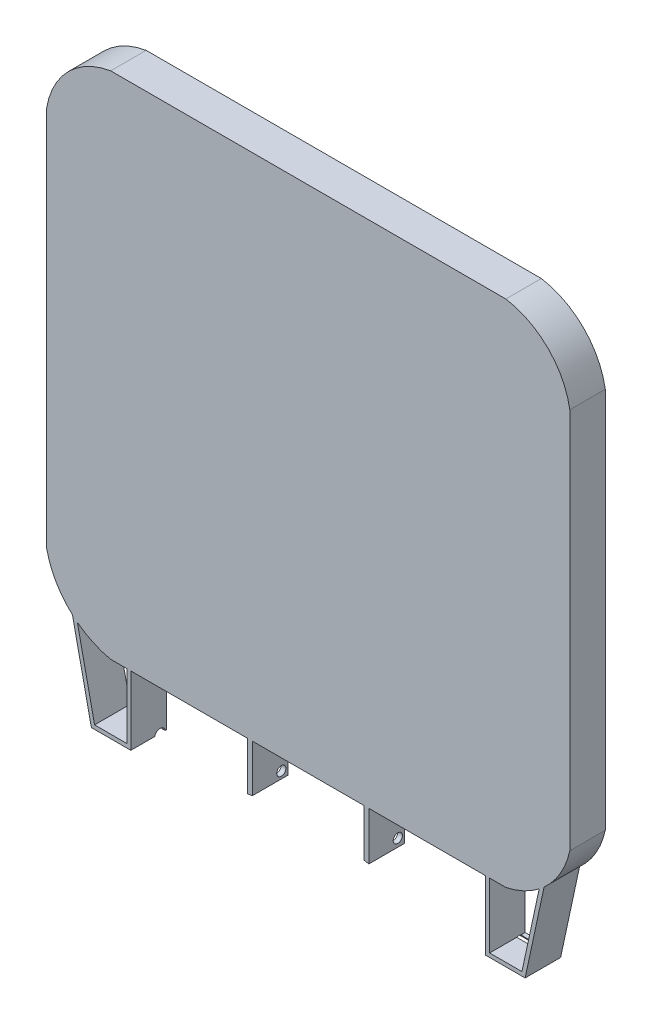
from build123d import *

# Parameters (mm, degrees)
BOSS_EXTRUDE1_DEPTH     = 25
BOSS_EXTRUDE2_DEPTH     = 2
BOSS_EXTRUDE3_DEPTH     = 27
SKETCH4_R               = 4.000000001
CUT_EXTRUDE1_DEPTH      = 290
CUT_EXTRUDE1_DEPTH_BACK = 10
BOSS_EXTRUDE4_DEPTH     = 27
SKETCH6_R               = 3.5
CUT_EXTRUDE2_DEPTH      = 108


with BuildPart() as part:
    # Sketch1 → Boss-Extrude1 (new body)
    with BuildSketch(Plane.XY):
        with BuildLine():
            Line((-199, 125.145211216), (-199, -165.423939983))
            ThreePointArc((-199, -165.423939983), (-181.870436917, -196.8510269), (-150.43197765, -213.959708975))
            Line((-150.43197765, -213.959708975), (150.431977646, -213.959708975))
            ThreePointArc((150.431977646, -213.959708975), (181.870436916, -196.8510269), (199, -165.423939981))
            Line((199, -165.423939981), (199, 125.145211216))
            ThreePointArc((199, 125.145211216), (182.477306779, 157.278075491), (150.333498342, 173.779467463))
            Line((150.333498342, 173.779467463), (-150.333498342, 173.779467463))
            ThreePointArc((-150.333498342, 173.779467463), (-182.477306779, 157.278075491), (-199, 125.145211216))
        make_face()
        with BuildLine():
            Line((-195, 124.810354463), (-195, -164.990595976))
            add(Edge.make_bspline(
                [(-195, -164.990595976), (-195, -209.959708976), (-150, -209.959708975)],
                knots=[3.141592654, 3.141592654, 3.141592654, 4.71238898, 4.71238898, 4.71238898], degree=2, weights=[1, 0.707106781, 1]))
            Line((-150, -209.959708975), (149.999999997, -209.959708975))
            add(Edge.make_bspline(
                [(149.999999997, -209.959708975), (195.000000002, -209.959708979), (195, -164.990595974)],
                knots=[4.71238898, 4.71238898, 4.71238898, 6.283185307, 6.283185307, 6.283185307], degree=2, weights=[1, 0.707106781, 1]))
            Line((195, -164.990595974), (195, 124.810354463))
            add(Edge.make_bspline(
                [(195, 124.810354463), (195, 169.779467463), (150, 169.779467463)],
                knots=[3.141592654, 3.141592654, 3.141592654, 4.71238898, 4.71238898, 4.71238898], degree=2, weights=[1, 0.707106781, 1]))
            Line((150, 169.779467463), (-150, 169.779467463))
            add(Edge.make_bspline(
                [(-150, 169.779467463), (-195, 169.779467463), (-195, 124.810354463)],
                knots=[1.570796327, 1.570796327, 1.570796327, 3.141592654, 3.141592654, 3.141592654], degree=2, weights=[1, 0.707106781, 1]))
        make_face(mode=Mode.SUBTRACT)
    extrude(amount=BOSS_EXTRUDE1_DEPTH)

    # Sketch2 → Boss-Extrude2 (add)
    with BuildSketch(Plane.XY.offset(25)):
        with BuildLine():
            Line((-199, 125.145211216), (-199, -165.423939983))
            ThreePointArc((-199, -165.423939983), (-181.870436917, -196.8510269), (-150.43197765, -213.959708975))
            Line((-150.43197765, -213.959708975), (150.431977646, -213.959708975))
            ThreePointArc((150.431977646, -213.959708975), (181.870436916, -196.8510269), (199, -165.423939981))
            Line((199, -165.423939981), (199, 125.145211216))
            ThreePointArc((199, 125.145211216), (182.477306779, 157.278075491), (150.333498342, 173.779467463))
            Line((150.333498342, 173.779467463), (-150.333498342, 173.779467463))
            ThreePointArc((-150.333498342, 173.779467463), (-182.477306779, 157.278075491), (-199, 125.145211216))
        make_face()
    extrude(amount=BOSS_EXTRUDE2_DEPTH)

    # Sketch3 → Boss-Extrude3 (add)
    with BuildSketch(Plane.XY.offset(27)):
        Polygon((-135, -204), (-135, -266.298841042), (-165, -266.298841042), (-180.688480604, -193.256655723), (-181.013326297, -190.888401224), (-177.05169199, -193.894319256), (-177.05169199, -195.902858929), (-162.575940018, -263.298841042), (-138, -263.298841042), (-138, -204), align=None)
    boss_extrude3 = extrude(amount=-BOSS_EXTRUDE3_DEPTH)

    # Mirror1: Boss-Extrude3 across plane
    add(boss_extrude3.mirror(Plane(origin=(0, 0, 0), x_dir=(0, 0, 1), z_dir=(1, 0, 0))))

    # Sketch4 → Cut-Extrude1 (cut, two sides)
    with BuildSketch(Plane(origin=(-135, 0, 0), x_dir=(0, 0, -1), z_dir=(1, 0, 0))) as cut_extrude1_sk:
        with Locations((-4.790160487, -266.968568277)):
            Circle(SKETCH4_R)
    extrude(amount=CUT_EXTRUDE1_DEPTH, mode=Mode.SUBTRACT)
    extrude(cut_extrude1_sk.sketch, amount=-CUT_EXTRUDE1_DEPTH_BACK, mode=Mode.SUBTRACT)

    # Sketch5 → Boss-Extrude4 (add)
    with BuildSketch(Plane.XY.offset(27)):
        Polygon((-46.130462584, -213.959708975), (-46.130462584, -250.580628677), (-42.5, -249.943543539), (-42.5, -213.959708975), align=None)
        Polygon((46.130462584, -250.580628677), (42.5, -249.943543539), (42.5, -213.959708975), (46.130462584, -213.959708975), align=None)
    extrude(amount=-BOSS_EXTRUDE4_DEPTH)

    # Sketch6 → Cut-Extrude2 (cut)
    with BuildSketch(Plane(origin=(46.130462584, 0, 0), x_dir=(0, 0, -1), z_dir=(1, 0, 0))):
        with Locations((-4.999999906, -244.580628739)):
            Circle(SKETCH6_R)
    extrude(amount=-CUT_EXTRUDE2_DEPTH, mode=Mode.SUBTRACT)


solid = part.part
